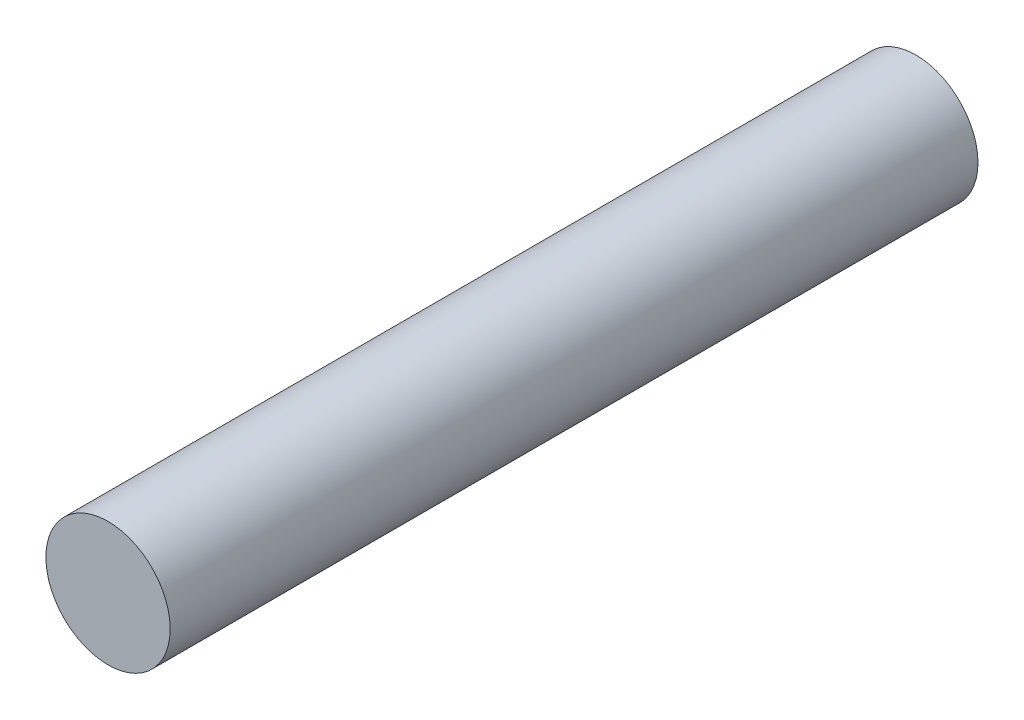
from build123d import *

# Parameters (mm, degrees)
SKETCH1_R           = 1
BOSS_EXTRUDE1_DEPTH = 13


with BuildPart() as part:
    # Sketch1 → Boss-Extrude1 (new body)
    with BuildSketch(Plane.XY):
        Circle(SKETCH1_R)
    extrude(amount=BOSS_EXTRUDE1_DEPTH)


solid = part.part
